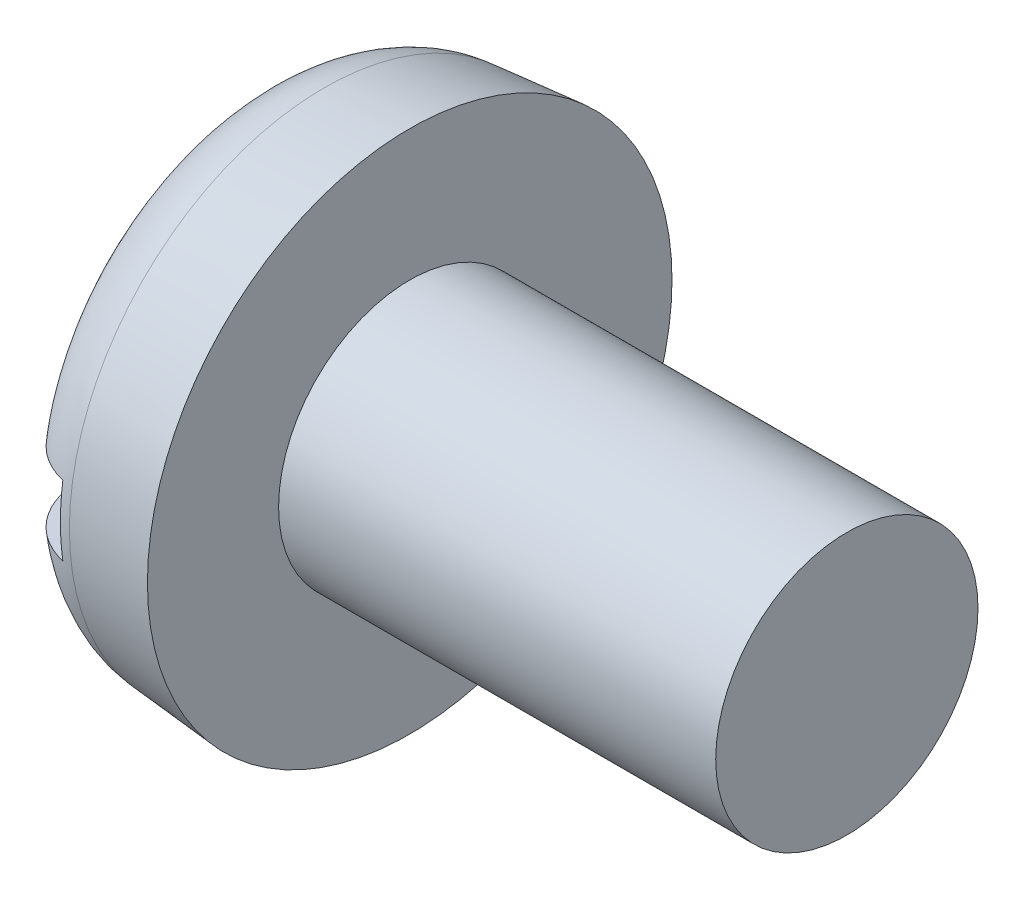
from build123d import *

# Parameters (mm, degrees)
FILLET2_R  = 1.8
SKETCH2_W  = 12
SKETCH2_H  = 1.6
SLOT_DEPTH = 1.4


with BuildPart() as part:
    # BodySke → Base-Revolve (revolve)
    with BuildSketch(Plane.XY, mode=Mode.PRIVATE) as base_revolve_sk:
        Polygon((3.6, 3), (3.6, 6), (0, 5.685040811), (0, 0), (13.6, 0), (13.6, 3), align=None)
    revolve(base_revolve_sk.sketch.rotate(Axis((-25.4, 0, 0), (1, 0, 0)), 90), axis=Axis((-25.4, 0, 0), (1, 0, 0)))  # turned: the seam where the file's is

    # Fillet2
    fillet2_edges = [part.edges().sort_by_distance(p)[0] for p in [
        (0, 0, -5.685040811),
    ]]
    fillet(fillet2_edges, radius=FILLET2_R)

    # Sketch2 → Slot (cut)
    with BuildSketch(Plane(origin=(0, 0, 0), x_dir=(0, 0, -1), z_dir=(1, 0, 0))):
        Rectangle(SKETCH2_W, SKETCH2_H)
    extrude(amount=SLOT_DEPTH, mode=Mode.SUBTRACT)


solid = part.part
